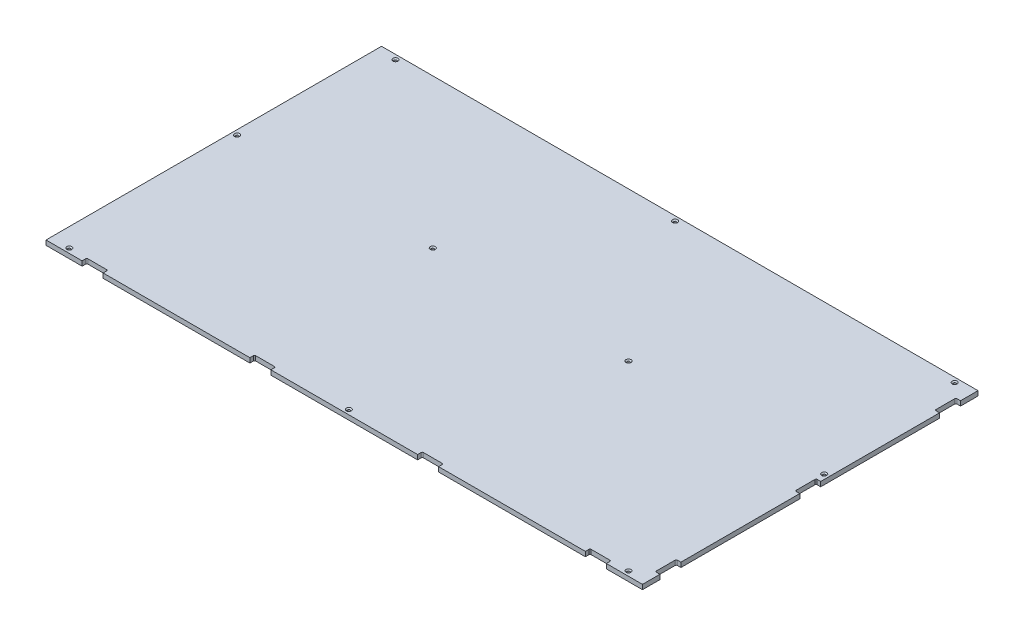
from build123d import *

# Parameters (mm, degrees)
SKETCH1_W                                           = 1625.6
SKETCH1_H                                           = 914.4
BOSS_EXTRUDE1_DEPTH                                 = 12.7
CSK_FOR_1_4_FLAT_HEAD_MACHINE_SCREW_100_D           = 7.14248
CSK_FOR_1_4_FLAT_HEAD_MACHINE_SCREW_100_CSINK_D     = 13.716
CSK_FOR_1_4_FLAT_HEAD_MACHINE_SCREW_100_CSINK_ANGLE = 100
SKETCH5_W                                           = 57.15
SKETCH5_H                                           = 12.7
CUT_EXTRUDE1_DEPTH                                  = 13.7
LPATTERN1_COUNT                                     = 4
LPATTERN1_PITCH                                     = 457.2
SKETCH6_W                                           = 12.7
SKETCH6_H                                           = 57.15
CUT_EXTRUDE2_DEPTH                                  = 13.7
LPATTERN2_COUNT                                     = 3
LPATTERN2_PITCH                                     = 381
FILLET1_R                                           = 3.175


with BuildPart() as part:
    # Sketch1 → Boss-Extrude1 (new body)
    with BuildSketch(Plane(origin=(0, 0, 0), x_dir=(1, 0, 0), z_dir=(0, 1, 0))):
        with Locations((812.8, 457.2)):
            Rectangle(SKETCH1_W, SKETCH1_H)
    extrude(amount=BOSS_EXTRUDE1_DEPTH)

    # CSK for 1/4 Flat Head Machine Screw (100)1 (through all)
    with Locations(Plane(origin=(0, 12.7, 0), x_dir=(1, 0, 0), z_dir=(0, 1, 0))):
        with Locations((12.7, 508), (50.8, 901.7), (546.1, 508), (812.8, 901.7), (1079.5, 508), (1574.8, 901.7), (1612.9, 508), (1574.8, 12.7), (812.8, 12.7), (50.8, 12.7)):
            CounterSinkHole(CSK_FOR_1_4_FLAT_HEAD_MACHINE_SCREW_100_D / 2, CSK_FOR_1_4_FLAT_HEAD_MACHINE_SCREW_100_CSINK_D / 2, counter_sink_angle=CSK_FOR_1_4_FLAT_HEAD_MACHINE_SCREW_100_CSINK_ANGLE)

    # Sketch5 → Cut-Extrude1 (cut, through all)
    with BuildSketch(Plane(origin=(0, 12.7, 0), x_dir=(1, 0, 0), z_dir=(0, 1, 0))):
        with Locations((127, 6.35)):
            Rectangle(SKETCH5_W, SKETCH5_H)
    cut_extrude1 = extrude(amount=-CUT_EXTRUDE1_DEPTH, mode=Mode.SUBTRACT)

    # LPattern1: Cut-Extrude1 ×4
    with Locations(*[(i * LPATTERN1_PITCH, 0, 0) for i in range(1, LPATTERN1_COUNT)]):
        add(cut_extrude1, mode=Mode.SUBTRACT)

    # Sketch6 → Cut-Extrude2 (cut, through all)
    with BuildSketch(Plane(origin=(0, 12.7, 0), x_dir=(1, 0, 0), z_dir=(0, 1, 0))):
        with Locations((1619.25, 76.2)):
            Rectangle(SKETCH6_W, SKETCH6_H)
    cut_extrude2 = extrude(amount=-CUT_EXTRUDE2_DEPTH, mode=Mode.SUBTRACT)

    # LPattern2: Cut-Extrude2 ×3
    with Locations(*[(0, 0, -i * LPATTERN2_PITCH) for i in range(1, LPATTERN2_COUNT)]):
        add(cut_extrude2, mode=Mode.SUBTRACT)

    # Fillet1
    fillet1_edges = [part.edges().sort_by_distance(p)[0] for p in [
        (98.425, 6.35, -12.7),
        (155.575, 6.35, -12.7),
        (555.625, 6.35, -12.7),
        (612.775, 6.35, -12.7),
        (1012.825, 6.35, -12.7),
        (1069.975, 6.35, -12.7),
        (1470.025, 6.35, -12.7),
        (1527.175, 6.35, -12.7),
        (1612.9, 6.35, -47.625),
        (1612.9, 6.35, -104.775),
        (1612.9, 6.35, -428.625),
        (1612.9, 6.35, -485.775),
        (1612.9, 6.35, -809.625),
        (1612.9, 6.35, -866.775),
    ]]
    fillet(fillet1_edges, radius=FILLET1_R)


solid = part.part
